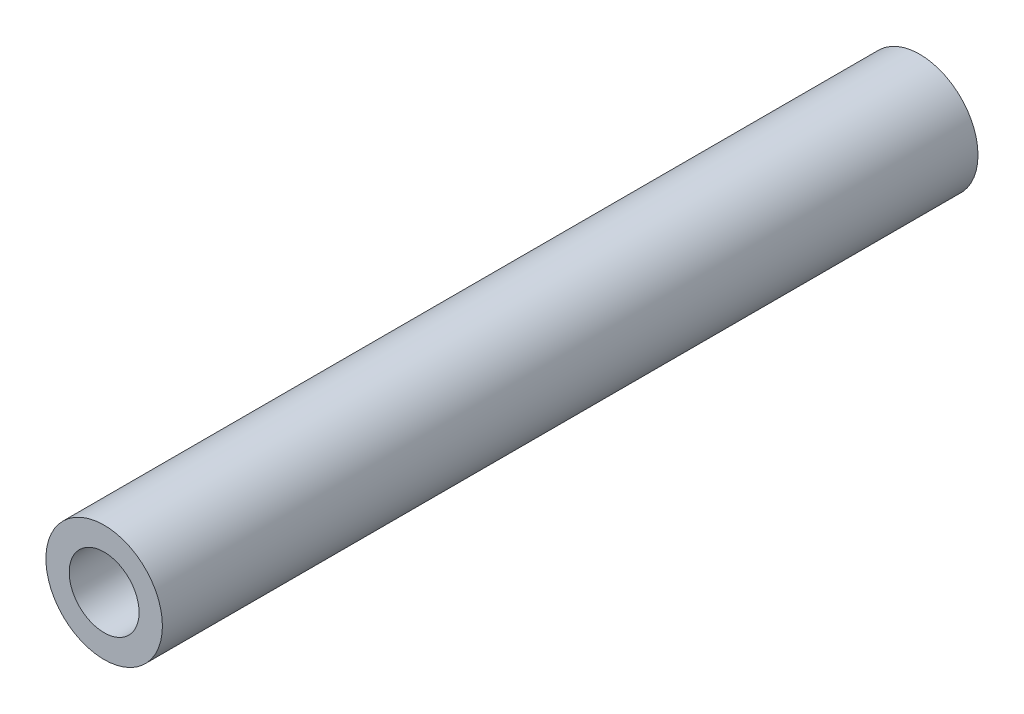
from build123d import *

# Parameters (mm, degrees)
SKETCH_1_R      = 2.5
SKETCH_1_R_2    = 1.5
EXTRUDE_1_DEPTH = 17.5


with BuildPart() as part:
    # 草图1 → 凸台-拉伸1 (new body, symmetric)
    with BuildSketch(Plane.XY):
        Circle(SKETCH_1_R)
        Circle(SKETCH_1_R_2, mode=Mode.SUBTRACT)
    extrude(amount=EXTRUDE_1_DEPTH, both=True)


solid = part.part
